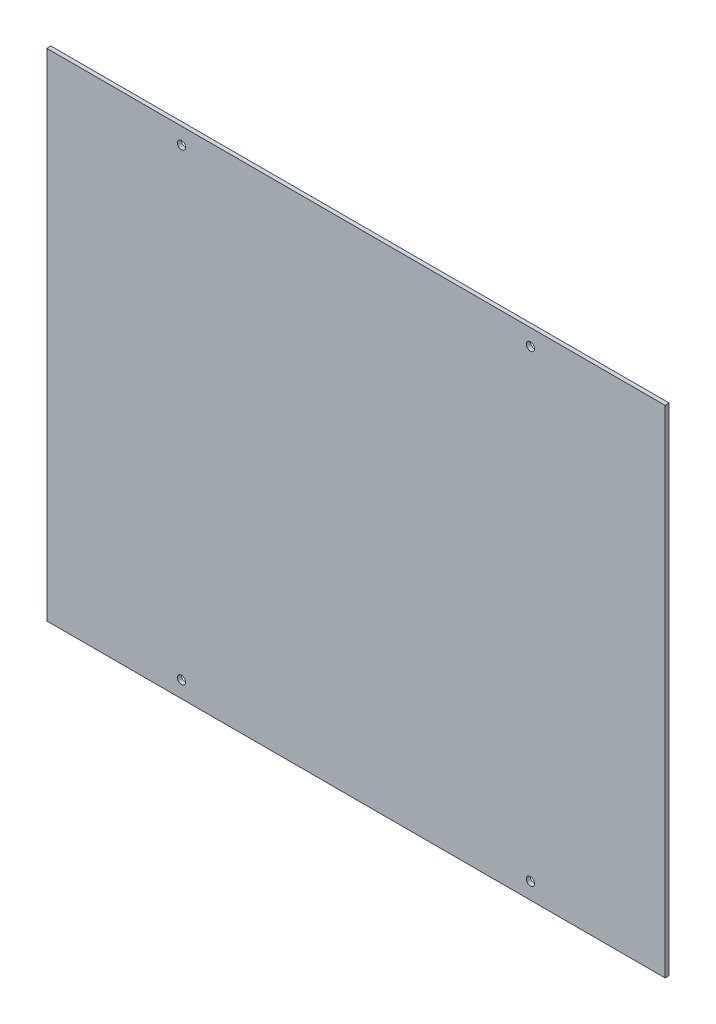
from build123d import *

# Parameters (mm, degrees)
SKETCH1_W           = 303
SKETCH1_H           = 243
SKETCH1_R           = 2
BOSS_EXTRUDE1_DEPTH = 2


with BuildPart() as part:
    # Sketch1 → Boss-Extrude1 (new body)
    with BuildSketch(Plane.XY):
        Rectangle(SKETCH1_W, SKETCH1_H)
        with Locations((-85.5, 113.48019802)):
            Circle(SKETCH1_R, mode=Mode.SUBTRACT)
        with Locations((85.5, 113.48019802)):
            Circle(SKETCH1_R, mode=Mode.SUBTRACT)
        with Locations((85.5, -113.48019802)):
            Circle(SKETCH1_R, mode=Mode.SUBTRACT)
        with Locations((-85.5, -113.48019802)):
            Circle(SKETCH1_R, mode=Mode.SUBTRACT)
    extrude(amount=BOSS_EXTRUDE1_DEPTH)


solid = part.part
